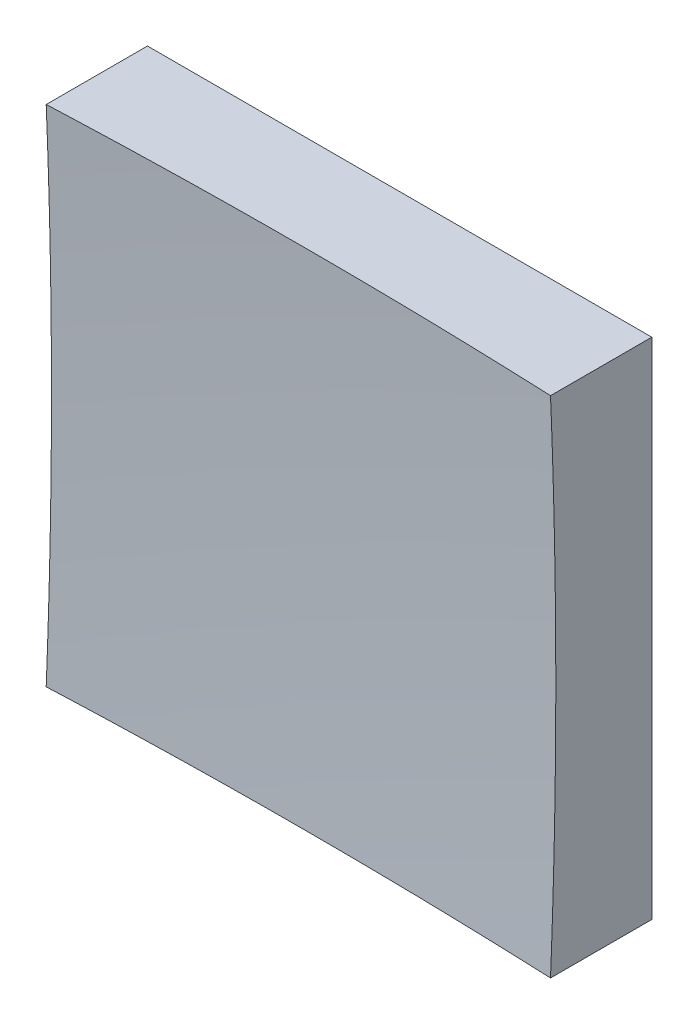
from build123d import *

# Parameters (mm, degrees)
SKETCH_1_W      = 50
SKETCH_1_H      = 50
EXTRUDE_1_DEPTH = 50


with BuildPart() as part:
    # 草图1 → 凸台-拉伸1 (new body)
    with BuildSketch(Plane.XY):
        Rectangle(SKETCH_1_W, SKETCH_1_H)
    extrude(amount=EXTRUDE_1_DEPTH)

    # 草图2 → 切除-旋转2 (revolve, cut)
    with BuildSketch(Plane(origin=(0, 0, 0), x_dir=(1, 0, 0), z_dir=(0, 1, 0))):
        with BuildLine():
            Line((584.907277088, -475.27088122), (0, -475.27088122))
            Line((0, -475.27088122), (0, -9))
            ThreePointArc((0, -9), (374.007037856, -139.83186848), (584.907277088, -475.27088122))
        make_face()
    revolve(axis=Axis((0, 0, 475.27088122), (0, 0, -1)), mode=Mode.SUBTRACT)


solid = part.part
